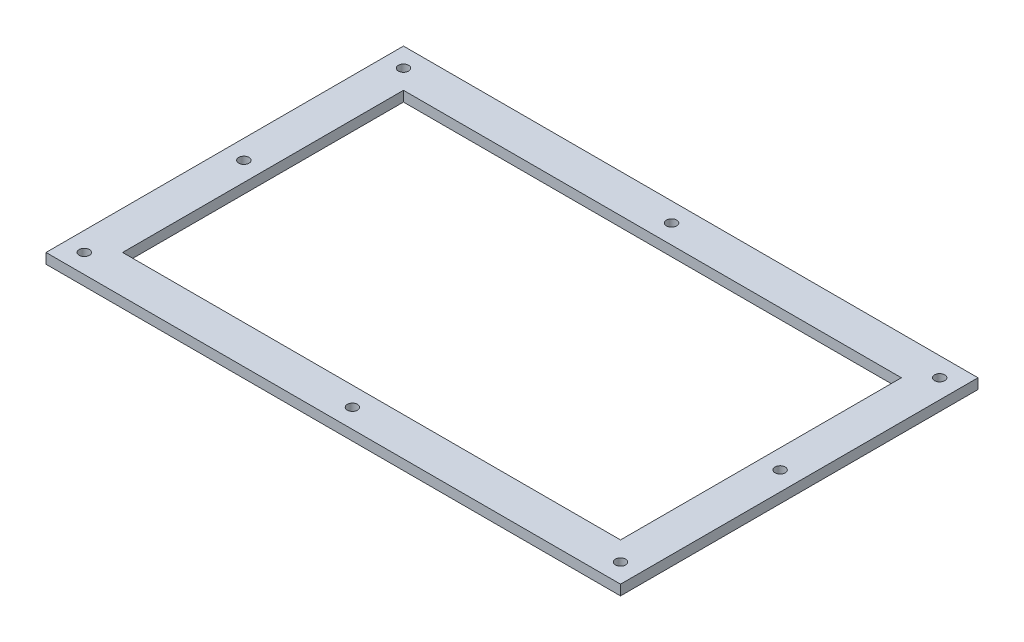
from build123d import *

# Parameters (mm, degrees)
SKETCH1_W           = 225
SKETCH1_H           = 140
SKETCH1_R           = 2
SKETCH1_W_2         = 195
SKETCH1_H_2         = 110
BOSS_EXTRUDE1_DEPTH = 4


with BuildPart() as part:
    # Sketch1 → Boss-Extrude1 (new body)
    with BuildSketch(Plane(origin=(0, 0, 0), x_dir=(1, 0, 0), z_dir=(0, 1, 0))):
        with Locations((27.5, 0)):
            Rectangle(SKETCH1_W, SKETCH1_H)
        with Locations((-77.5, -62.5)):
            Circle(SKETCH1_R, mode=Mode.SUBTRACT)
        with Locations((-77.5, 62.5)):
            Circle(SKETCH1_R, mode=Mode.SUBTRACT)
        with Locations((132.5, 62.5)):
            Circle(SKETCH1_R, mode=Mode.SUBTRACT)
        with Locations((132.5, -62.5)):
            Circle(SKETCH1_R, mode=Mode.SUBTRACT)
        with Locations((27.5, -62.5)):
            Circle(SKETCH1_R, mode=Mode.SUBTRACT)
        with Locations((27.5, 62.5)):
            Circle(SKETCH1_R, mode=Mode.SUBTRACT)
        with Locations((-77.5, 0)):
            Circle(SKETCH1_R, mode=Mode.SUBTRACT)
        with Locations((132.5, 0)):
            Circle(SKETCH1_R, mode=Mode.SUBTRACT)
        with Locations((27.5, 0)):
            Rectangle(SKETCH1_W_2, SKETCH1_H_2, mode=Mode.SUBTRACT)
    extrude(amount=BOSS_EXTRUDE1_DEPTH)


solid = part.part
